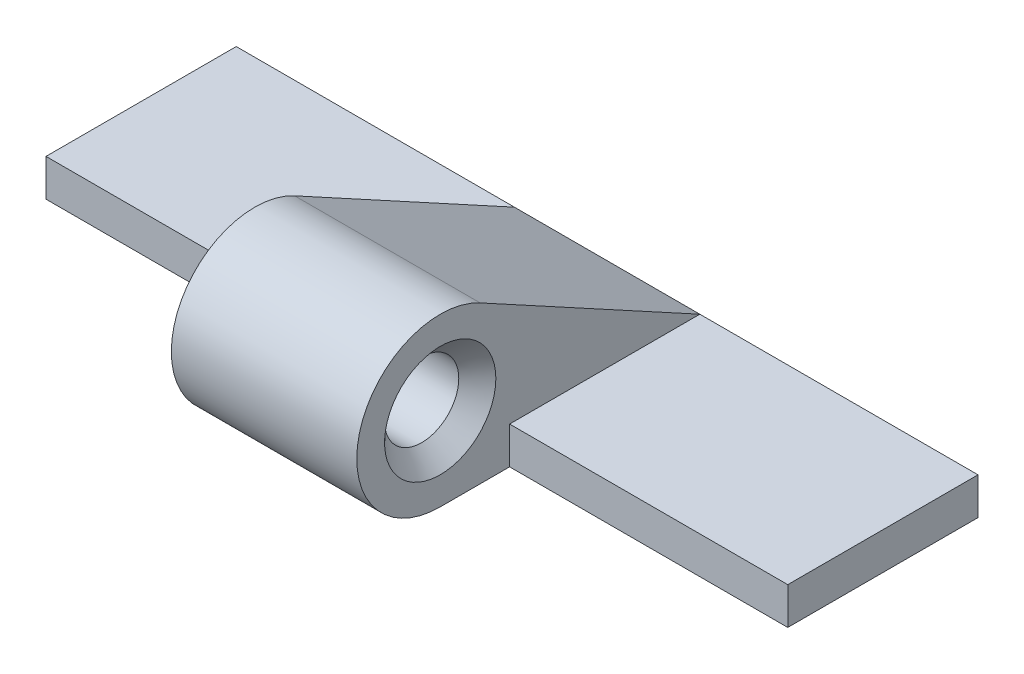
from build123d import *

# Parameters (mm, degrees)
SKIZZE2_W                       = 15
SKIZZE2_H                       = 7
AUFSATZ_LINEAR_AUSTRAGEN1_DEPTH = 1
SKIZZE3_R                       = 2.25
SKIZZE3_R_2                     = 1
AUFSATZ_LINEAR_AUSTRAGEN2_DEPTH = 15
SCHNITT_LINEAR_AUSTRAGEN1_DEPTH = 5
LINEARES_MUSTER1_COUNT          = 2
LINEARES_MUSTER1_PITCH          = 10
SKIZZE7_W                       = 5.129171307
SKIZZE7_H                       = 1
VERBREITERUNG_DEPTH             = 2.5
FASE1_SIZE                      = 0.5
AUFSATZ_LINEAR_AUSTRAGEN3_DEPTH = 5


with BuildPart() as part:
    # Skizze2 → Aufsatz-Linear austragen1 (new body)
    with BuildSketch(Plane(origin=(0, 0, 0), x_dir=(1, 0, 0), z_dir=(0, 1, 0))):
        Rectangle(SKIZZE2_W, SKIZZE2_H)
    extrude(amount=AUFSATZ_LINEAR_AUSTRAGEN1_DEPTH)

    # Skizze3 → Aufsatz-Linear austragen2 (add)
    with BuildSketch(Plane(origin=(7.5, 0, 0), x_dir=(0, 0, -1), z_dir=(1, 0, 0))):
        with Locations((-3.5, 2.25)):
            Circle(SKIZZE3_R)
        with Locations((-3.5, 2.25)):
            Circle(SKIZZE3_R_2, mode=Mode.SUBTRACT)
    extrude(amount=-AUFSATZ_LINEAR_AUSTRAGEN2_DEPTH)

    # Skizze5 → Schnitt-Linear austragen1 (cut)
    with BuildSketch(Plane(origin=(7.5, 0, 0), x_dir=(0, 0, -1), z_dir=(1, 0, 0))):
        with BuildLine():
            Line((-1.629171307, 1), (-1.629171307, 0))
            Line((-1.629171307, 0), (-3.5, 0))
            ThreePointArc((-3.5, 0), (-4.560660172, 4.234313483), (-1.629171307, 1))
        make_face()
    schnitt_linear_austragen1 = extrude(amount=-SCHNITT_LINEAR_AUSTRAGEN1_DEPTH, mode=Mode.SUBTRACT)

    # Lineares Muster1: Schnitt-Linear austragen1 ×2
    with Locations(*[(-i * LINEARES_MUSTER1_PITCH, 0, 0) for i in range(1, LINEARES_MUSTER1_COUNT)]):
        add(schnitt_linear_austragen1, mode=Mode.SUBTRACT)

    # Skizze7 → Verbreiterung (add)
    with BuildSketch(Plane(origin=(7.5, 0, 0), x_dir=(0, 0, -1), z_dir=(1, 0, 0))):
        with Locations((0.935414346, 0.5)):
            Rectangle(SKIZZE7_W, SKIZZE7_H)
    verbreiterung = extrude(amount=VERBREITERUNG_DEPTH)

    # Spiegeln1: Verbreiterung across plane
    add(verbreiterung.mirror(Plane(origin=(0, 0, 0), x_dir=(0, 0, 1), z_dir=(1, 0, 0))))

    # Fase1
    fase1_edges = [part.edges().sort_by_distance(p)[0] for p in [
        (2.5, 2.25, 4.5),
        (-2.5, 2.25, 4.5),
    ]]
    chamfer(fase1_edges, length=FASE1_SIZE)

    # Skizze9 → Aufsatz-Linear austragen3 (add)
    with BuildSketch(Plane(origin=(2.5, 0, 0), x_dir=(0, 0, -1), z_dir=(1, 0, 0))):
        Polygon((-1.629171307, 1), (3.5, 1), (-2.423928807, 4.225998681), align=None)
    extrude(amount=-AUFSATZ_LINEAR_AUSTRAGEN3_DEPTH)


solid = part.part
